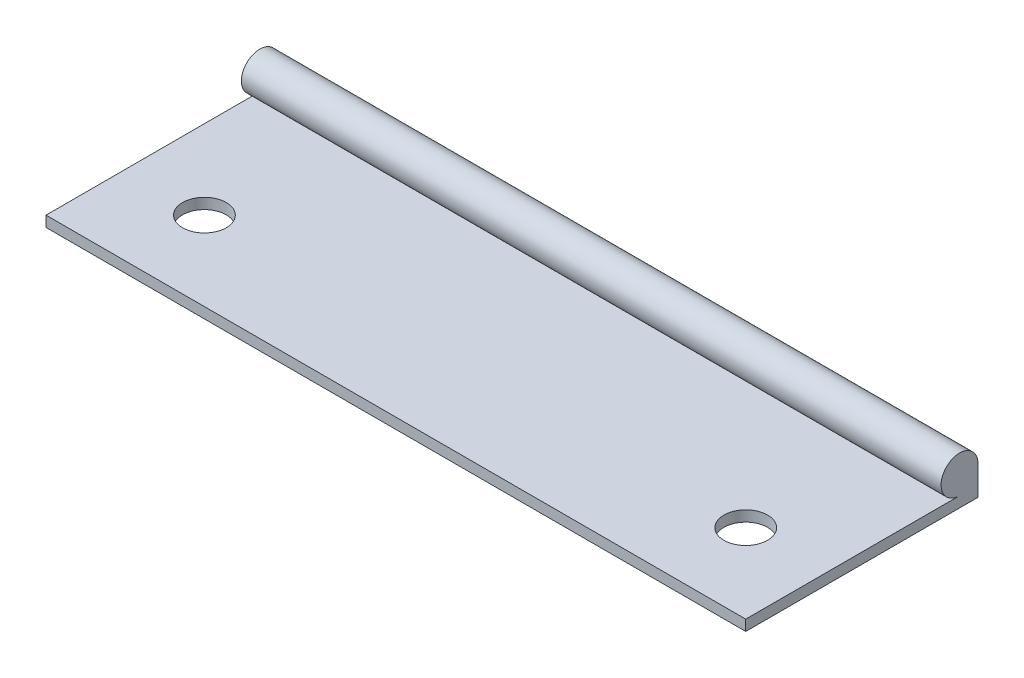
from build123d import *

# Parameters (mm, degrees)
SKETCH_1_R          = 1.9
EXTRUDE_1_DEPTH     = 72
SKETCH_2_R          = 2.25
CUT_EXTRUDE_1_DEPTH = 2.1


with BuildPart() as part:
    # 草图1 → 凸台-拉伸1 (new body)
    with BuildSketch(Plane(origin=(0, 0, 0), x_dir=(0, 0, -1), z_dir=(1, 0, 0))):
        with Locations((22, 3)):
            Circle(SKETCH_1_R)
        with BuildLine():
            Line((0, 1.1), (0, 0))
            Line((0, 0), (19, 0))
            Line((19, 0), (23.9, 0))
            Line((23.9, 0), (23.9, 3))
            ThreePointArc((23.9, 3), (23.343502884, 1.656497116), (22, 1.1))
            Line((22, 1.1), (19, 1.1))
            Line((19, 1.1), (0, 1.1))
        make_face()
    extrude(amount=EXTRUDE_1_DEPTH)

    # 草图2 → 切除-拉伸1 (cut, through all)
    with BuildSketch(Plane(origin=(0, 1.1, 0), x_dir=(1, 0, 0), z_dir=(0, 1, 0))):
        with Locations((8.15, 8.15)):
            Circle(SKETCH_2_R)
        with Locations((63.85, 8.15)):
            Circle(SKETCH_2_R)
    extrude(amount=-CUT_EXTRUDE_1_DEPTH, mode=Mode.SUBTRACT)


solid = part.part
